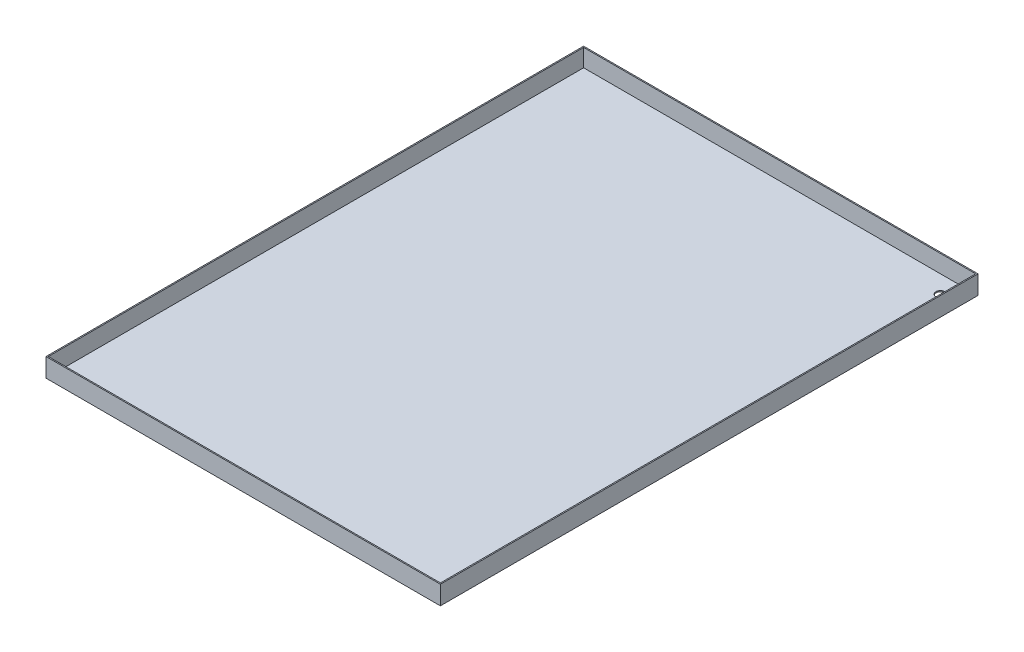
from build123d import *

# Parameters (mm, degrees)
SKETCH1_W           = 559
SKETCH1_H           = 762
BOSS_EXTRUDE1_DEPTH = 1.6
SKETCH2_W           = 559
SKETCH2_H           = 762
SKETCH2_W_2         = 555.8
SKETCH2_H_2         = 758.8
BOSS_EXTRUDE2_DEPTH = 25
SKETCH3_R           = 6.35
CUT_EXTRUDE1_DEPTH  = 2.6


with BuildPart() as part:
    # Sketch1 → Boss-Extrude1 (new body)
    with BuildSketch(Plane(origin=(0, 0, 0), x_dir=(1, 0, 0), z_dir=(0, 1, 0))):
        with Locations((279.5, 381)):
            Rectangle(SKETCH1_W, SKETCH1_H)
    extrude(amount=BOSS_EXTRUDE1_DEPTH)

    # Sketch2 → Boss-Extrude2 (add)
    with BuildSketch(Plane(origin=(0, 1.6, 0), x_dir=(1, 0, 0), z_dir=(0, 1, 0))):
        with Locations((279.5, 381)):
            Rectangle(SKETCH2_W, SKETCH2_H)
        with Locations((279.5, 381)):
            Rectangle(SKETCH2_W_2, SKETCH2_H_2, mode=Mode.SUBTRACT)
    extrude(amount=BOSS_EXTRUDE2_DEPTH)

    # Sketch3 → Cut-Extrude1 (cut, through all)
    with BuildSketch(Plane(origin=(0, 1.6, 0), x_dir=(1, 0, 0), z_dir=(0, 1, 0))):
        with Locations((532.4, 735.4)):
            Circle(SKETCH3_R)
    extrude(amount=-CUT_EXTRUDE1_DEPTH, mode=Mode.SUBTRACT)


solid = part.part
